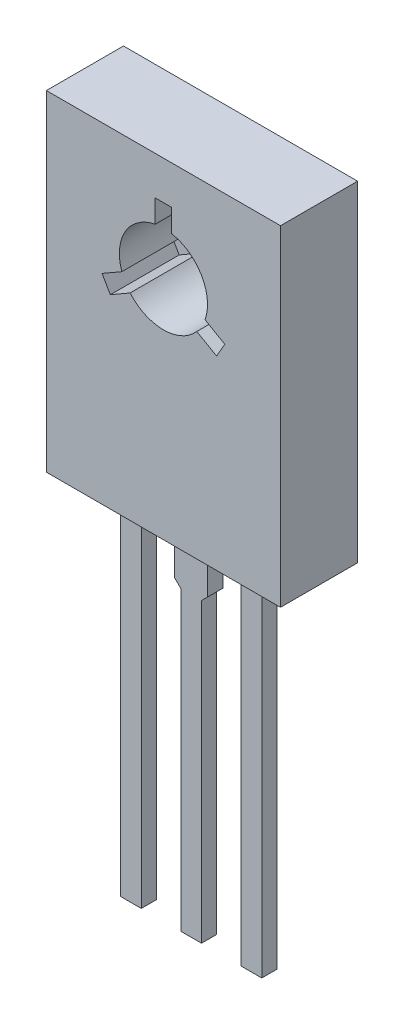
from build123d import *

# Parameters (mm, degrees)
SKETCH1_W           = 8.5
SKETCH1_H           = 12
SKETCH1_R           = 1.6
BOSS_EXTRUDE1_DEPTH = 2.8
CUT_EXTRUDE1_DEPTH  = 2.5
SKETCH3_W           = 0.75
SKETCH3_H           = 0.55
BOSS_EXTRUDE2_DEPTH = 13
BOSS_EXTRUDE3_DEPTH = 0.55
SKETCH5_W           = 6
SKETCH5_H           = 8
SKETCH5_R           = 1.6
BOSS_EXTRUDE4_DEPTH = 0.001


with BuildPart() as part:
    # Sketch1 → Boss-Extrude1 (new body)
    with BuildSketch(Plane.XY):
        with Locations((4.25, -6)):
            Rectangle(SKETCH1_W, SKETCH1_H)
        with Locations((4.25, -3.8)):
            Circle(SKETCH1_R, mode=Mode.SUBTRACT)
    extrude(amount=BOSS_EXTRUDE1_DEPTH)

    # Sketch2 → Cut-Extrude1 (cut)
    with BuildSketch(Plane.XY.offset(2.8)):
        with BuildLine():
            Line((2.321539031, -5.259807621), (3.038934241, -4.845619303))
            ThreePointArc((3.038934241, -4.845619303), (2.864359354, -4.6), (2.738934241, -4.326004061))
            Line((2.738934241, -4.326004061), (2.021539031, -4.740192379))
            Line((2.021539031, -4.740192379), (2.321539031, -5.259807621))
        make_face()
        with BuildLine():
            Line((6.178460969, -5.259807621), (6.478460969, -4.740192379))
            Line((6.478460969, -4.740192379), (5.761065759, -4.326004061))
            ThreePointArc((5.761065759, -4.326004061), (5.635640646, -4.6), (5.461065759, -4.845619303))
            Line((5.461065759, -4.845619303), (6.178460969, -5.259807621))
        make_face()
        with BuildLine():
            ThreePointArc((3.95, -2.228376635), (4.25, -2.2), (4.55, -2.228376635))
            Line((4.55, -2.228376635), (4.55, -1.4))
            Line((4.55, -1.4), (3.95, -1.4))
            Line((3.95, -1.4), (3.95, -2.228376635))
        make_face()
    extrude(amount=-CUT_EXTRUDE1_DEPTH, mode=Mode.SUBTRACT)

    # Sketch3 → Boss-Extrude2 (add)
    with BuildSketch(Plane.XZ.offset(12)):
        with Locations((2.065, 1.519799242)):
            Rectangle(SKETCH3_W, SKETCH3_H)
        with Locations((4.252122452, 1.519799242)):
            Rectangle(SKETCH3_W, SKETCH3_H)
        with Locations((6.439244903, 1.519799242)):
            Rectangle(SKETCH3_W, SKETCH3_H)
    extrude(amount=BOSS_EXTRUDE2_DEPTH)

    # Sketch4 → Boss-Extrude3 (add)
    with BuildSketch(Plane.XY.offset(1.794799242)):
        Polygon((3.652122452, -14), (4.152122452, -14.5), (4.352122452, -14.5), (4.852122452, -14), (4.852122452, -12), (3.652122452, -12), align=None)
    extrude(amount=-BOSS_EXTRUDE3_DEPTH)

    # Sketch5 → Boss-Extrude4 (add)
    with BuildSketch(Plane(origin=(0, 0, 0), x_dir=(-1, 0, 0), z_dir=(0, 0, -1))):
        with Locations((-4.25, -5)):
            Rectangle(SKETCH5_W, SKETCH5_H)
        with Locations((-4.25, -3.8)):
            Circle(SKETCH5_R, mode=Mode.SUBTRACT)
    extrude(amount=BOSS_EXTRUDE4_DEPTH)


solid = part.part
